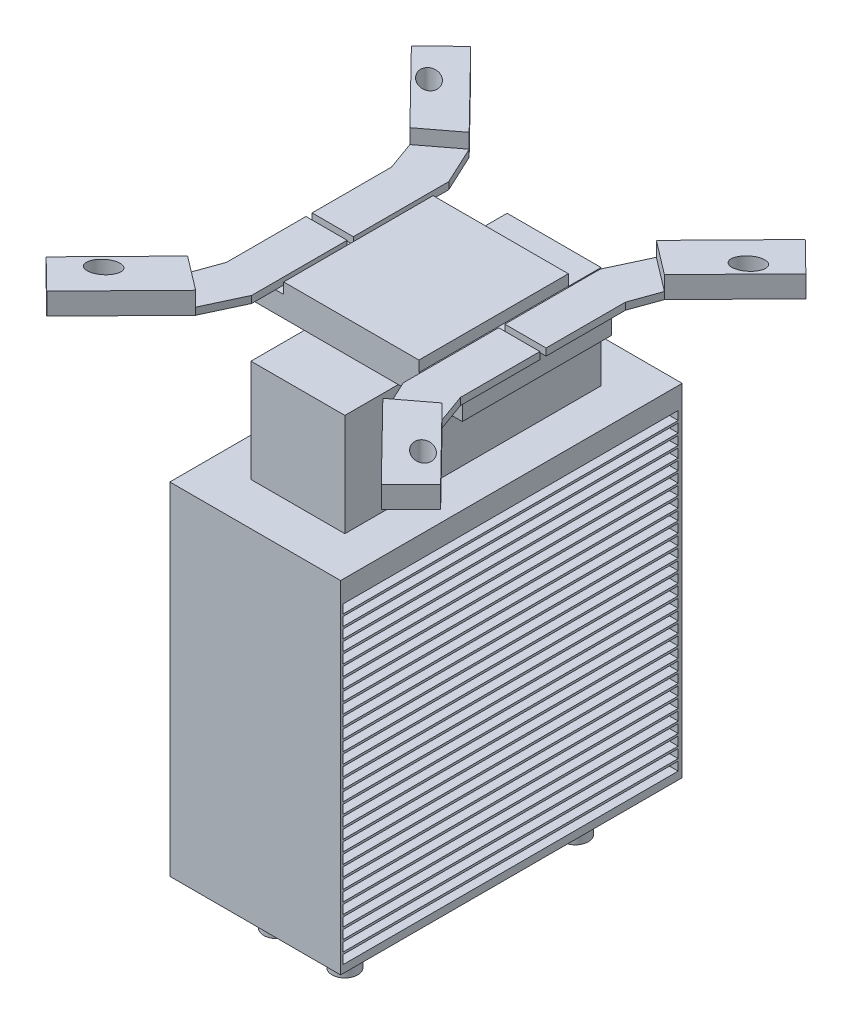
from build123d import *

# Parameters (mm, degrees)
SKETCH1_W              = 40
SKETCH1_H              = 80
BOSS_EXTRUDE1_DEPTH    = 80
SKETCH2_R              = 3
BOSS_EXTRUDE2_DEPTH    = 11
SKETCH7_W              = 22
SKETCH7_H              = 60
BOSS_EXTRUDE4_DEPTH    = 24
SKETCH8_W              = 52
SKETCH8_H              = 35
BOSS_EXTRUDE5_DEPTH    = 4.86
SKETCH9_W              = 31.68
SKETCH9_H              = 35
BOSS_EXTRUDE6_DEPTH    = 2.54
BOSS_EXTRUDE9_DEPTH    = 1.651
SKETCH11_RX            = 3.374766507
SKETCH11_RY            = 2.200108998
BOSS_EXTRUDE10_DEPTH   = 5.08
BOSS_EXTRUDE10_2_DEPTH = 5.08
BOSS_EXTRUDE10_3_DEPTH = 5.08
BOSS_EXTRUDE10_4_DEPTH = 5.08
SKETCH12_W             = 78.488418751
SKETCH12_H             = 2.032
CUT_EXTRUDE1_DEPTH     = 142.154087554


with BuildPart() as part:
    # Sketch1 → Boss-Extrude1 (new body)
    with BuildSketch(Plane(origin=(0, 0, 0), x_dir=(1, 0, 0), z_dir=(0, 1, 0))):
        with Locations((-32.127066409, -0.947148945)):
            Rectangle(SKETCH1_W, SKETCH1_H)
    extrude(amount=BOSS_EXTRUDE1_DEPTH)

    # Sketch2 → Boss-Extrude2 (add)
    with BuildSketch(Plane.XZ):
        with Locations((-40.127066409, 27.947148945)):
            Circle(SKETCH2_R)
        with Locations((-40.127066409, -26.052851055)):
            Circle(SKETCH2_R)
        with Locations((-24.127066409, 27.947148945)):
            Circle(SKETCH2_R)
        with Locations((-24.127066409, -26.052851055)):
            Circle(SKETCH2_R)
    extrude(amount=BOSS_EXTRUDE2_DEPTH)

    # Sketch7 → Boss-Extrude4 (add)
    with BuildSketch(Plane(origin=(0, 80, 0), x_dir=(1, 0, 0), z_dir=(0, 1, 0))):
        with Locations((-32.127066409, -0.947148945)):
            Rectangle(SKETCH7_W, SKETCH7_H)
    extrude(amount=BOSS_EXTRUDE4_DEPTH)

    # Sketch8 → Boss-Extrude5 (add)
    with BuildSketch(Plane(origin=(0, 104, 0), x_dir=(1, 0, 0), z_dir=(0, 1, 0))):
        with Locations((-32.127066409, -0.947148945)):
            Rectangle(SKETCH8_W, SKETCH8_H)
    extrude(amount=BOSS_EXTRUDE5_DEPTH)

    # Sketch9 → Boss-Extrude6 (add)
    with BuildSketch(Plane(origin=(0, 108.86, 0), x_dir=(1, 0, 0), z_dir=(0, 1, 0))):
        with Locations((-32.127066409, -0.947148945)):
            Rectangle(SKETCH9_W, SKETCH9_H)
    extrude(amount=BOSS_EXTRUDE6_DEPTH)

    # Sketch10 → Boss-Extrude9 (add)
    with BuildSketch(Plane(origin=(0, 108.86, 0), x_dir=(1, 0, 0), z_dir=(0, 1, 0))):
        Polygon((-14.382066409, -1.672148945), (-4.730066409, -1.672148945), (-4.730066409, -20.290348945), (-2.320182887, -26.981612309), (-10.204868605, -32.978325337), (-14.382066409, -24.024148945), align=None)
        Polygon((-14.382066409, -0.222148945), (-4.730066409, -0.222148945), (-4.730066409, 18.396051055), (-2.320182887, 25.08731442), (-10.204868605, 31.084027448), (-14.382066409, 22.129851055), align=None)
        Polygon((-49.872066409, 22.129851055), (-54.049264213, 31.084027448), (-61.93394993, 25.08731442), (-59.524066409, 18.396051055), (-59.524066409, -0.222148945), (-49.872066409, -0.222148945), align=None)
        Polygon((-59.524066409, -20.290348945), (-61.93394993, -26.981612309), (-54.049264213, -32.978325337), (-49.872066409, -24.024148945), (-49.872066409, -1.672148945), (-59.524066409, -1.672148945), align=None)
    extrude(amount=BOSS_EXTRUDE9_DEPTH)

    # Sketch12 → Cut-Extrude1 (cut, through all)
    with BuildSketch(Plane(origin=(-12.127066409, 0, 0), x_dir=(0, 0, -1), z_dir=(1, 0, 0))):
        with Locations((-1.133364117, 71.409675219)):
            Rectangle(SKETCH12_W, SKETCH12_H)
        with Locations((-1.133364117, 73.949675219)):
            Rectangle(SKETCH12_W, SKETCH12_H)
        with Locations((-1.133364117, 68.869675219)):
            Rectangle(SKETCH12_W, SKETCH12_H)
        with Locations((-1.133364117, 66.329675219)):
            Rectangle(SKETCH12_W, SKETCH12_H)
        with Locations((-1.133364117, 63.789675219)):
            Rectangle(SKETCH12_W, SKETCH12_H)
        with Locations((-1.133364117, 61.249675219)):
            Rectangle(SKETCH12_W, SKETCH12_H)
        with Locations((-1.133364117, 58.709675219)):
            Rectangle(SKETCH12_W, SKETCH12_H)
        with Locations((-1.133364117, 56.169675219)):
            Rectangle(SKETCH12_W, SKETCH12_H)
        with Locations((-1.133364117, 53.629675219)):
            Rectangle(SKETCH12_W, SKETCH12_H)
        with Locations((-1.133364117, 51.089675219)):
            Rectangle(SKETCH12_W, SKETCH12_H)
        with Locations((-1.133364117, 48.549675219)):
            Rectangle(SKETCH12_W, SKETCH12_H)
        with Locations((-1.133364117, 46.009675219)):
            Rectangle(SKETCH12_W, SKETCH12_H)
        with Locations((-1.133364117, 43.469675219)):
            Rectangle(SKETCH12_W, SKETCH12_H)
        with Locations((-1.133364117, 40.929675219)):
            Rectangle(SKETCH12_W, SKETCH12_H)
        with Locations((-1.133364117, 38.389675219)):
            Rectangle(SKETCH12_W, SKETCH12_H)
        with Locations((-1.133364117, 35.849675219)):
            Rectangle(SKETCH12_W, SKETCH12_H)
        with Locations((-1.133364117, 33.309675219)):
            Rectangle(SKETCH12_W, SKETCH12_H)
        with Locations((-1.133364117, 30.769675219)):
            Rectangle(SKETCH12_W, SKETCH12_H)
        with Locations((-1.133364117, 28.229675219)):
            Rectangle(SKETCH12_W, SKETCH12_H)
        with Locations((-1.133364117, 25.689675219)):
            Rectangle(SKETCH12_W, SKETCH12_H)
        with Locations((-1.133364117, 23.149675219)):
            Rectangle(SKETCH12_W, SKETCH12_H)
        with Locations((-1.133364117, 20.609675219)):
            Rectangle(SKETCH12_W, SKETCH12_H)
        with Locations((-1.133364117, 18.069675219)):
            Rectangle(SKETCH12_W, SKETCH12_H)
        with Locations((-1.133364117, 15.529675219)):
            Rectangle(SKETCH12_W, SKETCH12_H)
        with Locations((-1.133364117, 12.989675219)):
            Rectangle(SKETCH12_W, SKETCH12_H)
        with Locations((-1.133364117, 10.449675219)):
            Rectangle(SKETCH12_W, SKETCH12_H)
        with Locations((-1.133364117, 7.909675219)):
            Rectangle(SKETCH12_W, SKETCH12_H)
        with Locations((-1.133364117, 5.369675219)):
            Rectangle(SKETCH12_W, SKETCH12_H)
        with Locations((-1.133364117, 2.829675219)):
            Rectangle(SKETCH12_W, SKETCH12_H)
    extrude(amount=-CUT_EXTRUDE1_DEPTH, mode=Mode.SUBTRACT)


with BuildPart() as body_2:
    # Sketch11 → Boss-Extrude10 (new body)
    with BuildSketch(Plane.XZ.offset(-108.86)):
        Polygon((-61.93394993, -25.08731442), (-78.324945895, -41.824992231), (-71.302401264, -48.702081276), (-54.049264213, -31.084027448), align=None)
        with Locations(Location((-69.528566409, -37.152851055), (0, 0, 37.559425541))):
            Ellipse(SKETCH11_RX, SKETCH11_RY, mode=Mode.SUBTRACT)
    extrude(amount=-BOSS_EXTRUDE10_DEPTH)


with BuildPart() as body_3:
    # Sketch11 → Boss-Extrude10 2 (new body)
    with BuildSketch(Plane.XZ.offset(-108.86)):
        Polygon((-61.93394993, 26.981612309), (-78.324945895, 43.719290121), (-71.302401264, 50.596379165), (-54.049264213, 32.978325337), align=None)
        with Locations(Location((-69.528566409, 39.047148945), (0, 0, 142.440574459))):
            Ellipse(SKETCH11_RX, SKETCH11_RY, mode=Mode.SUBTRACT)
    extrude(amount=-BOSS_EXTRUDE10_2_DEPTH)


with BuildPart() as body_4:
    # Sketch11 → Boss-Extrude10 3 (new body)
    with BuildSketch(Plane.XZ.offset(-108.86)):
        Polygon((7.048268447, 50.596379165), (14.070813078, 43.719290121), (-2.320182887, 26.981612309), (-10.204868605, 32.978325337), align=None)
        with Locations(Location((5.274433591, 39.047148945), (0, 0, 37.559425541))):
            Ellipse(SKETCH11_RX, SKETCH11_RY, mode=Mode.SUBTRACT)
    extrude(amount=-BOSS_EXTRUDE10_3_DEPTH)


with BuildPart() as body_5:
    # Sketch11 → Boss-Extrude10 4 (new body)
    with BuildSketch(Plane.XZ.offset(-108.86)):
        Polygon((7.048268447, -48.702081276), (14.070813078, -41.824992231), (-2.320182887, -25.08731442), (-10.204868605, -31.084027448), align=None)
        with Locations(Location((5.274433591, -37.152851055), (0, 0, -37.559425541))):
            Ellipse(SKETCH11_RX, SKETCH11_RY, mode=Mode.SUBTRACT)
    extrude(amount=-BOSS_EXTRUDE10_4_DEPTH)


solid = Compound([part.part, body_2.part, body_3.part, body_4.part, body_5.part])
